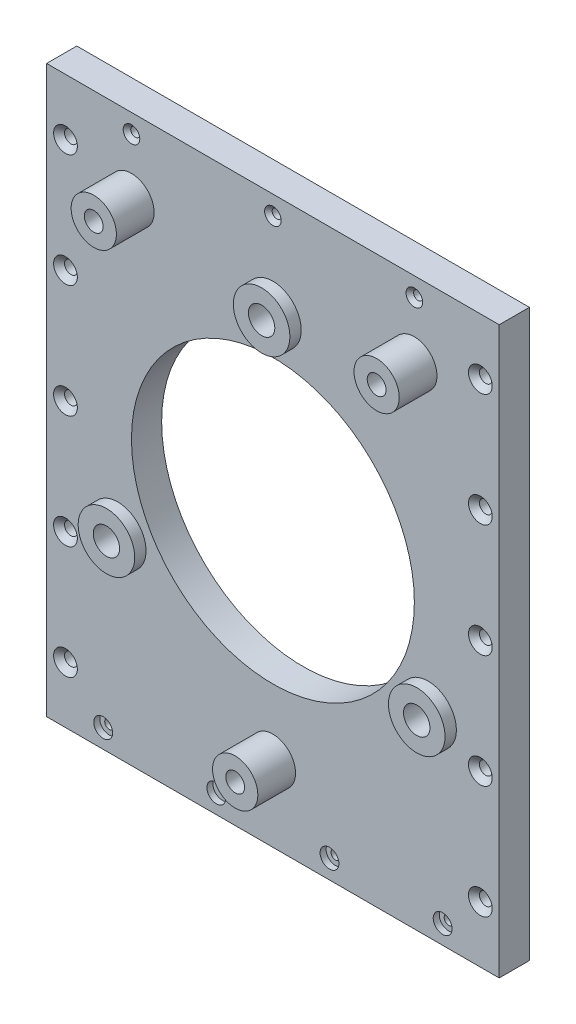
from build123d import *

# Parameters (mm, degrees)
SKETCH1_W                                     = 120
SKETCH1_H                                     = 150
EXTRUDE1_DEPTH                                = 8
SKETCH2_R                                     = 37.5
EXTRUDE2_DEPTH                                = 9
SKETCH3_R                                     = 7.5
EXTRUDE3_DEPTH                                = 3
SKETCH4_R                                     = 6
EXTRUDE4_DEPTH                                = 10
TAPPED_HOLE1_D                                = 4.2
TAPPED_HOLE1_DEPTH                            = 14
TAPPED_HOLE1_CBORE_D                          = 5
TAPPED_HOLE1_CBORE_DEPTH                      = 10
TAPPED_HOLE1_TIP                              = 1.2618073
SKETCH7_R                                     = 3.5
EXTRUDE5_DEPTH                                = 12
CSK_FOR_FLAT_HEAD_MACHINE_SCREW1_D            = 3.4
CSK_FOR_FLAT_HEAD_MACHINE_SCREW1_CSINK_D      = 6.3
CSK_FOR_FLAT_HEAD_MACHINE_SCREW1_CSINK_ANGLE  = 90
LPATTERN1_COUNT                               = 5
LPATTERN1_PITCH                               = 30
LPATTERN1_COUNT_DIR2                          = 2
LPATTERN1_PITCH_DIR2                          = 110
CBORE_FOR_PAN_HEAD_MACHINE_SCREW2_D           = 2.4
CBORE_FOR_PAN_HEAD_MACHINE_SCREW2_CBORE_D     = 5
CBORE_FOR_PAN_HEAD_MACHINE_SCREW2_CBORE_DEPTH = 1.6
LPATTERN2_COUNT                               = 4
LPATTERN2_PITCH                               = 30
CSK_FOR_FLAT_HEAD_MACHINE_SCREW2_D            = 2.4
CSK_FOR_FLAT_HEAD_MACHINE_SCREW2_CSINK_D      = 4.4
CSK_FOR_FLAT_HEAD_MACHINE_SCREW2_CSINK_ANGLE  = 90
LPATTERN3_COUNT                               = 3
LPATTERN3_PITCH                               = 37.5


with BuildPart() as part:
    # Sketch1 → Extrude1 (new body)
    with BuildSketch(Plane.XY):
        with Locations((60, 75)):
            Rectangle(SKETCH1_W, SKETCH1_H)
    extrude(amount=-EXTRUDE1_DEPTH)

    # Sketch2 → Extrude2 (cut, through all)
    with BuildSketch(Plane.XY):
        with Locations((60, 75)):
            Circle(SKETCH2_R)
    extrude(amount=-EXTRUDE2_DEPTH, mode=Mode.SUBTRACT)

    # Sketch3 → Extrude3 (add)
    with BuildSketch(Plane.XY):
        with Locations((60, 122.5)):
            Circle(SKETCH3_R)
        with Locations((101.13620668, 51.25)):
            Circle(SKETCH3_R)
        with Locations((18.86379332, 51.25)):
            Circle(SKETCH3_R)
    extrude(amount=EXTRUDE3_DEPTH)

    # Sketch4 → Extrude4 (add)
    with BuildSketch(Plane.XY):
        with Locations((22.5, 130)):
            Circle(SKETCH4_R)
        with Locations((97.5, 130)):
            Circle(SKETCH4_R)
        with Locations((60, 20)):
            Circle(SKETCH4_R)
    extrude(amount=EXTRUDE4_DEPTH)

    # Tapped Hole1
    with Locations(Plane.XY.offset(10)):
        with Locations((22.5, 130), (97.5, 130), (60, 20)):
            CounterBoreHole(TAPPED_HOLE1_D / 2, TAPPED_HOLE1_CBORE_D / 2, TAPPED_HOLE1_CBORE_DEPTH, depth=TAPPED_HOLE1_DEPTH)
            with Locations((0, 0, -(TAPPED_HOLE1_DEPTH + TAPPED_HOLE1_TIP / 2))):  # 118° drill point
                Cone(0, TAPPED_HOLE1_D / 2, TAPPED_HOLE1_TIP, mode=Mode.SUBTRACT)

    # Sketch7 → Extrude5 (cut, through all)
    with BuildSketch(Plane.XY.offset(3)):
        with Locations((60, 122.5)):
            Circle(SKETCH7_R)
        with Locations((101.13620668, 51.25)):
            Circle(SKETCH7_R)
        with Locations((18.86379332, 51.25)):
            Circle(SKETCH7_R)
    extrude(amount=-EXTRUDE5_DEPTH, mode=Mode.SUBTRACT)

    # CSK for  Flat Head Machine Screw1 (through all)
    with Locations(Plane.XY):
        with Locations((5, 15)):
            csk_for_flat_head_machine_screw1 = CounterSinkHole(CSK_FOR_FLAT_HEAD_MACHINE_SCREW1_D / 2, CSK_FOR_FLAT_HEAD_MACHINE_SCREW1_CSINK_D / 2, counter_sink_angle=CSK_FOR_FLAT_HEAD_MACHINE_SCREW1_CSINK_ANGLE)

    # LPattern1: CSK for Flat Head Machine Screw1 5 × 2
    with Locations(*[(j * LPATTERN1_PITCH_DIR2, i * LPATTERN1_PITCH, 0) for i in range(LPATTERN1_COUNT) for j in range(LPATTERN1_COUNT_DIR2) if (i, j) != (0, 0)]):
        add(csk_for_flat_head_machine_screw1, mode=Mode.SUBTRACT)

    # CBORE for  Pan Head Machine Screw2 (through all)
    with Locations(Plane.XY):
        with Locations((15, 5)):
            cbore_for_pan_head_machine_screw2 = CounterBoreHole(CBORE_FOR_PAN_HEAD_MACHINE_SCREW2_D / 2, CBORE_FOR_PAN_HEAD_MACHINE_SCREW2_CBORE_D / 2, CBORE_FOR_PAN_HEAD_MACHINE_SCREW2_CBORE_DEPTH)

    # LPattern2: CBORE for  Pan Head Machine Screw2 ×4
    with Locations(*[(i * LPATTERN2_PITCH, 0, 0) for i in range(1, LPATTERN2_COUNT)]):
        add(cbore_for_pan_head_machine_screw2, mode=Mode.SUBTRACT)

    # CSK for  Flat Head Machine Screw2 (through all)
    with Locations(Plane.XY):
        with Locations((22.5, 145)):
            csk_for_flat_head_machine_screw2 = CounterSinkHole(CSK_FOR_FLAT_HEAD_MACHINE_SCREW2_D / 2, CSK_FOR_FLAT_HEAD_MACHINE_SCREW2_CSINK_D / 2, counter_sink_angle=CSK_FOR_FLAT_HEAD_MACHINE_SCREW2_CSINK_ANGLE)

    # LPattern3: CSK for  Flat Head Machine Screw2 ×3
    with Locations(*[(i * LPATTERN3_PITCH, 0, 0) for i in range(1, LPATTERN3_COUNT)]):
        add(csk_for_flat_head_machine_screw2, mode=Mode.SUBTRACT)


solid = part.part
